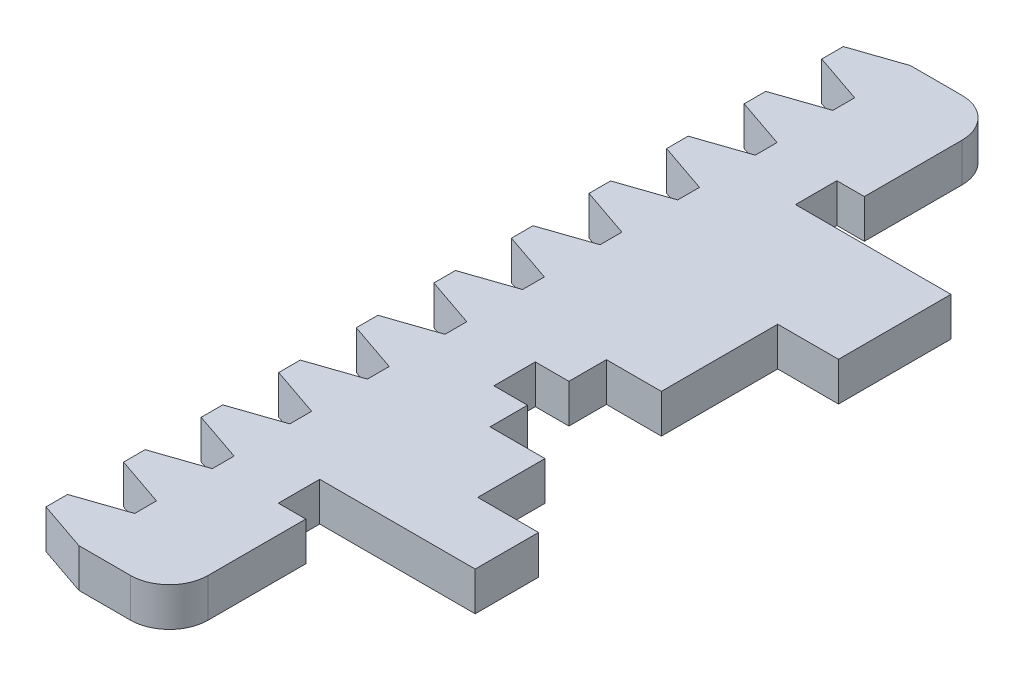
from build123d import *

# Parameters (mm, degrees)
BOSS_EXTRUDE1_DEPTH = 3
SKETCH4_W           = 12.125
SKETCH4_H           = 3.2
SKETCH4_W_2         = 4.8
SKETCH4_H_2         = 23.2
SKETCH4_W_3         = 2.7
CUT_EXTRUDE1_DEPTH  = 4


with BuildPart() as part:
    # Sketch1 → Boss-Extrude1 (new body)
    with BuildSketch(Plane(origin=(0, 0, 0), x_dir=(1, 0, 0), z_dir=(0, 1, 0))):
        with BuildLine():
            Line((37.95, 21.5), (28.05, 21.5))
            Line((28.05, 21.5), (28.05, 29.157009142))
            ThreePointArc((28.05, 29.157009142), (27.171320344, 31.278329486), (25.05, 32.157009142))
            Line((25.05, 32.157009142), (21.058452488, 32.157009142))
            Line((21.058452488, 32.157009142), (17.188733854, 30.83348742))
            Line((17.188733854, 30.83348742), (17.188733854, 29.16651258))
            Line((17.188733854, 29.16651258), (21.058452488, 27.842990858))
            Line((21.058452488, 27.842990858), (21.058452488, 26.157009142))
            Line((21.058452488, 26.157009142), (17.188733854, 24.83348742))
            Line((17.188733854, 24.83348742), (17.188733854, 23.16651258))
            Line((17.188733854, 23.16651258), (21.058452488, 21.842990858))
            Line((21.058452488, 21.842990858), (21.058452488, 20.157009142))
            Line((21.058452488, 20.157009142), (17.188733854, 18.83348742))
            Line((17.188733854, 18.83348742), (17.188733854, 17.16651258))
            Line((17.188733854, 17.16651258), (21.058452488, 15.842990858))
            Line((21.058452488, 15.842990858), (21.058452488, 14.157009142))
            Line((21.058452488, 14.157009142), (17.188733854, 12.83348742))
            Line((17.188733854, 12.83348742), (17.188733854, 11.16651258))
            Line((17.188733854, 11.16651258), (21.058452488, 9.842990858))
            Line((21.058452488, 9.842990858), (21.058452488, 8.157009142))
            Line((21.058452488, 8.157009142), (17.188733854, 6.83348742))
            Line((17.188733854, 6.83348742), (17.188733854, 5.16651258))
            Line((17.188733854, 5.16651258), (21.058452488, 3.842990858))
            Line((21.058452488, 3.842990858), (21.058452488, 2.157009142))
            Line((21.058452488, 2.157009142), (17.188733854, 0.83348742))
            Line((17.188733854, 0.83348742), (17.188733854, -0.83348742))
            Line((17.188733854, -0.83348742), (21.058452488, -2.157009142))
            Line((21.058452488, -2.157009142), (21.058452488, -3.842990858))
            Line((21.058452488, -3.842990858), (17.188733854, -5.16651258))
            Line((17.188733854, -5.16651258), (17.188733854, -6.83348742))
            Line((17.188733854, -6.83348742), (21.058452488, -8.157009142))
            Line((21.058452488, -8.157009142), (21.058452488, -9.842990858))
            Line((21.058452488, -9.842990858), (17.188733854, -11.16651258))
            Line((17.188733854, -11.16651258), (17.188733854, -12.83348742))
            Line((17.188733854, -12.83348742), (21.058452488, -14.157009142))
            Line((21.058452488, -14.157009142), (21.058452488, -15.842990858))
            Line((21.058452488, -15.842990858), (17.188733854, -17.16651258))
            Line((17.188733854, -17.16651258), (17.188733854, -18.83348742))
            Line((17.188733854, -18.83348742), (21.058452488, -20.157009142))
            Line((21.058452488, -20.157009142), (21.058452488, -21.842990858))
            Line((21.058452488, -21.842990858), (17.188733854, -23.16651258))
            Line((17.188733854, -23.16651258), (17.188733854, -24.83348742))
            Line((17.188733854, -24.83348742), (21.058452488, -26.157009142))
            Line((21.058452488, -26.157009142), (21.058452488, -27.842990858))
            Line((21.058452488, -27.842990858), (17.188733854, -29.16651258))
            Line((17.188733854, -29.16651258), (17.188733854, -30.83348742))
            Line((17.188733854, -30.83348742), (21.058452488, -32.157009142))
            Line((21.058452488, -32.157009142), (25.05, -32.157009142))
            ThreePointArc((25.05, -32.157009142), (27.171320344, -31.278329486), (28.05, -29.157009142))
            Line((28.05, -29.157009142), (28.05, -21.5))
            Line((28.05, -21.5), (37.95, -21.5))
            Line((37.95, -21.5), (37.95, -8.3))
            Line((37.95, -8.3), (29, -8.3))
            Line((29, -8.3), (29, 0.7))
            Line((29, 0.7), (37.95, 0.7))
            Line((37.95, 0.7), (37.95, 21.5))
        make_face()
    extrude(amount=-BOSS_EXTRUDE1_DEPTH)

    # Sketch4 → Cut-Extrude1 (cut, through all)
    with BuildSketch(Plane(origin=(0, 0, 0), x_dir=(1, 0, 0), z_dir=(0, 1, 0))):
        with Locations((31.9875, -20)):
            Rectangle(SKETCH4_W, SKETCH4_H)
        with Locations((35.65, -1.9)):
            Rectangle(SKETCH4_W_2, SKETCH4_H_2)
        with Locations((31.9875, 20)):
            Rectangle(SKETCH4_W, SKETCH4_H)
        with Locations((27.75, -3.8)):
            Rectangle(SKETCH4_W_3, SKETCH4_H)
    extrude(amount=-CUT_EXTRUDE1_DEPTH, mode=Mode.SUBTRACT)


solid = part.part
